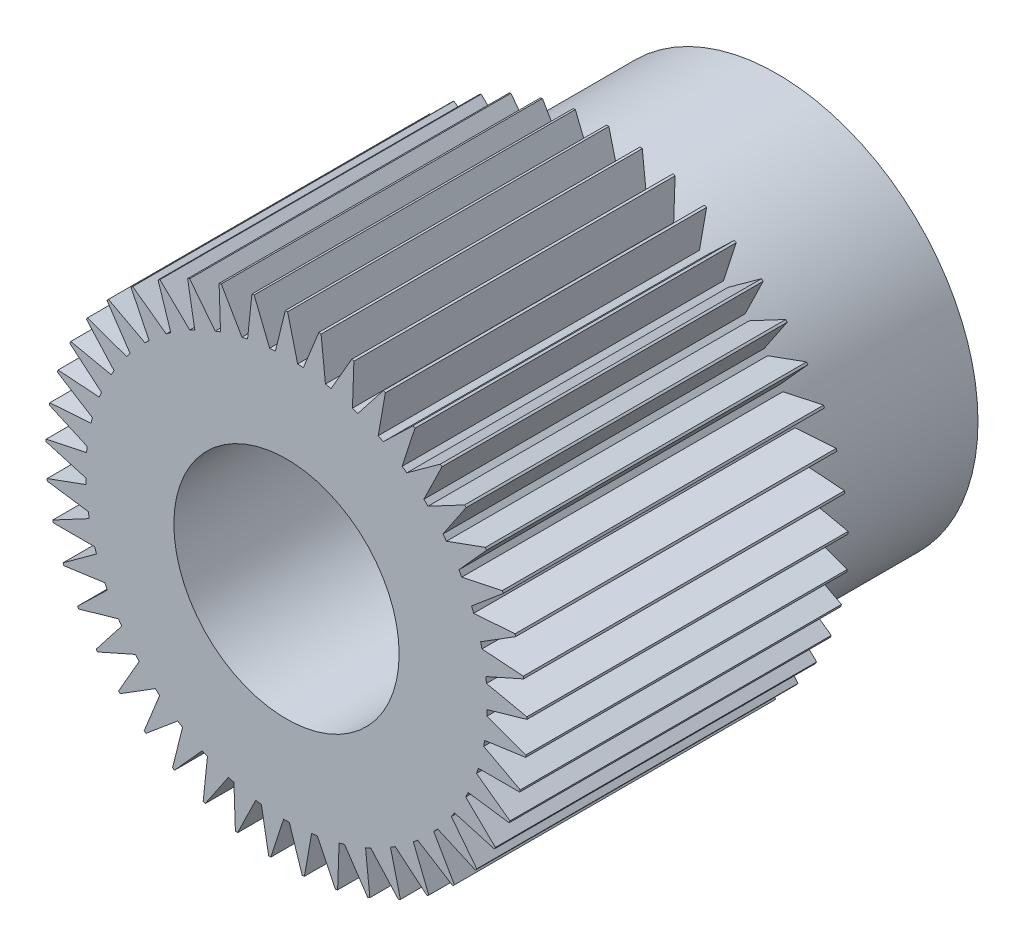
from build123d import *

# Parameters (mm, degrees)
SKETCH1_R           = 4.5
BOSS_EXTRUDE1_DEPTH = 11
SKETCH2_R           = 2.525
CUT_EXTRUDE1_DEPTH  = 12
BOSS_EXTRUDE2_DEPTH = 7.2
CIRPATTERN2_COUNT   = 45


with BuildPart() as part:
    # Sketch1 → Boss-Extrude1 (new body)
    with BuildSketch(Plane.XY):
        Circle(SKETCH1_R)
    extrude(amount=BOSS_EXTRUDE1_DEPTH)

    # Sketch2 → Cut-Extrude1 (cut, through all)
    with BuildSketch(Plane.XY.offset(11)):
        Circle(SKETCH2_R)
    extrude(amount=-CUT_EXTRUDE1_DEPTH, mode=Mode.SUBTRACT)

    # Sketch3 → Boss-Extrude2 (add)
    with BuildSketch(Plane.XY.offset(11)):
        with BuildLine():
            Line((-0.25, 4.493050189), (-0.025, 5.393050189))
            Line((-0.025, 5.393050189), (0.025, 5.393050189))
            Line((0.025, 5.393050189), (0.25, 4.493050189))
            ThreePointArc((0.25, 4.493050189), (0, 4.5), (-0.25, 4.493050189))
        make_face()
    boss_extrude2 = extrude(amount=-BOSS_EXTRUDE2_DEPTH)

    # CirPattern2: Boss-Extrude2 ×45 about axis
    cirpattern2_axis = Axis((0, 0, 0), (0, 0, 1))
    for i in range(1, CIRPATTERN2_COUNT):
        add(boss_extrude2.rotate(cirpattern2_axis, i * 360 / CIRPATTERN2_COUNT))


solid = part.part
